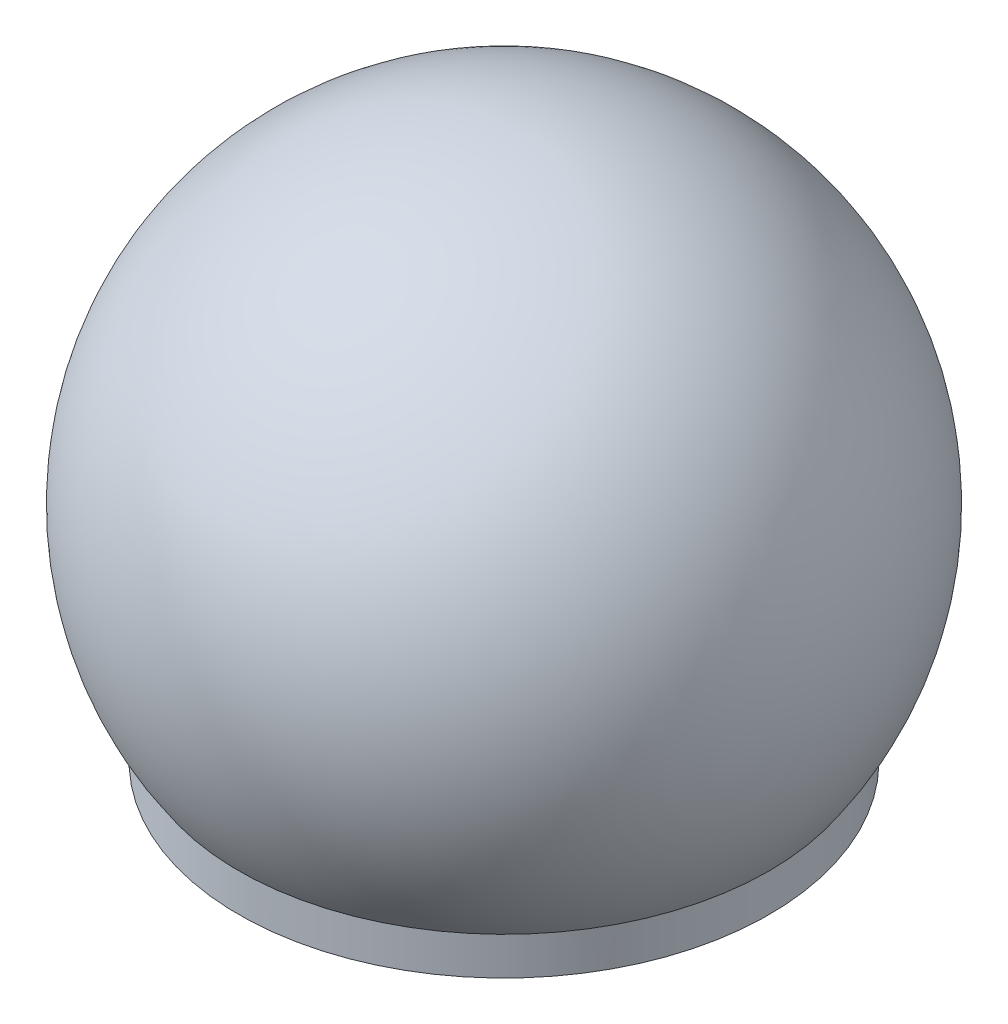
from build123d import *


with BuildPart() as part:
    # Sketch1 → Revolve1 (revolve)
    with BuildSketch(Plane.XY, mode=Mode.PRIVATE) as revolve1_sk:
        with BuildLine():
            Line((-1.5875, 0), (-22.225, 0))
            Line((-22.225, 0), (-22.225, 3.175))
            ThreePointArc((-22.225, 3.175), (-24.066125336, 31.265144421), (0, 45.868827772))
            Line((0, 45.868827772), (0, 42.813696551))
            Line((0, 42.813696551), (-6.35, 42.813696551))
            Line((-6.35, 42.813696551), (-21.1836, 21.629120278))
            Line((-21.1836, 21.629120278), (-25.374009401, 15.644595445))
            Line((-25.374009401, 15.644595445), (-21.1836, 3.175))
            Line((-21.1836, 3.175), (-21.1836, 2.1082))
            Line((-21.1836, 2.1082), (-6.35, 2.1082))
            Line((-6.35, 2.1082), (-6.35, 6.35))
            Line((-6.35, 6.35), (-1.5875, 6.35))
            Line((-1.5875, 6.35), (-1.5875, 2.1082))
            Line((-1.5875, 2.1082), (-1.5875, 0))
        make_face()
    revolve(revolve1_sk.sketch.rotate(Axis((0, 0, 0), (0, 1, 0)), 270), axis=Axis((0, 0, 0), (0, 1, 0)))


solid = part.part
